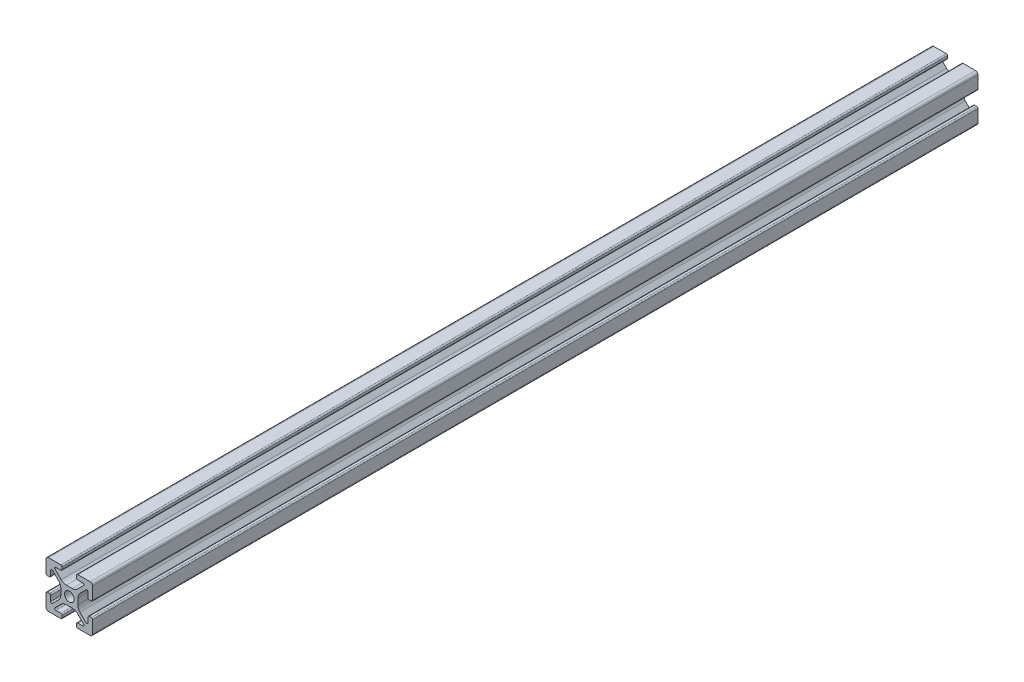
from build123d import *

# Parameters (mm, degrees)
SKETCH2_R           = 2.05
BOSS_EXTRUDE1_DEPTH = 380


with BuildPart() as part:
    # Sketch2 → Boss-Extrude1 (new body)
    with BuildSketch(Plane.XY):
        with BuildLine():
            Line((-3.642230561, 1.287773026), (-3.642230561, -1.287773026))
            ThreePointArc((-3.642230561, -1.287773026), (-3.87999308, -2.483085929), (-4.55708345, -3.496423279))
            Line((-4.55708345, -3.496423279), (-7.182004606, -6.121344434))
            ThreePointArc((-7.182004606, -6.121344434), (-7.704200045, -6.225215565), (-8, -5.782519648))
            Line((-8, -5.782519648), (-8, -3.622007668))
            ThreePointArc((-8, -3.622007668), (-8.161974206, -3.230967343), (-8.553014531, -3.068993137))
            Line((-8.553014531, -3.068993137), (-9.443284204, -3.068993137))
            ThreePointArc((-9.443284204, -3.068993137), (-9.836715763, -3.229656566), (-10, -3.622007668))
            Line((-10, -3.622007668), (-10, -8.939033256))
            ThreePointArc((-10, -8.939033256), (-9.689250035, -9.689250035), (-8.939033256, -10))
            Line((-8.939033256, -10), (-3.622007668, -10))
            ThreePointArc((-3.622007668, -10), (-3.229656566, -9.836715763), (-3.068993137, -9.443284204))
            Line((-3.068993137, -9.443284204), (-3.068993137, -8.553014531))
            ThreePointArc((-3.068993137, -8.553014531), (-3.230967343, -8.161974206), (-3.622007668, -8))
            Line((-3.622007668, -8), (-5.782519648, -8))
            ThreePointArc((-5.782519648, -8), (-6.225215565, -7.704200045), (-6.121344434, -7.182004606))
            Line((-6.121344434, -7.182004606), (-3.496423279, -4.55708345))
            ThreePointArc((-3.496423279, -4.55708345), (-2.483085929, -3.87999308), (-1.287773026, -3.642230561))
            Line((-1.287773026, -3.642230561), (1.287773026, -3.642230561))
            ThreePointArc((1.287773026, -3.642230561), (2.483085929, -3.87999308), (3.496423279, -4.55708345))
            Line((3.496423279, -4.55708345), (6.121344434, -7.182004606))
            ThreePointArc((6.121344434, -7.182004606), (6.225215565, -7.704200045), (5.782519648, -8))
            Line((5.782519648, -8), (3.622007668, -8))
            ThreePointArc((3.622007668, -8), (3.230967343, -8.161974206), (3.068993137, -8.553014531))
            Line((3.068993137, -8.553014531), (3.068993137, -9.443284204))
            ThreePointArc((3.068993137, -9.443284204), (3.229656566, -9.836715763), (3.622007668, -10))
            Line((3.622007668, -10), (8.939033256, -10))
            ThreePointArc((8.939033256, -10), (9.689250035, -9.689250035), (10, -8.939033256))
            Line((10, -8.939033256), (10, -3.622007668))
            ThreePointArc((10, -3.622007668), (9.836715763, -3.229656566), (9.443284204, -3.068993137))
            Line((9.443284204, -3.068993137), (8.553014531, -3.068993137))
            ThreePointArc((8.553014531, -3.068993137), (8.161974206, -3.230967343), (8, -3.622007668))
            Line((8, -3.622007668), (8, -5.782519648))
            ThreePointArc((8, -5.782519648), (7.704200045, -6.225215565), (7.182004606, -6.121344434))
            Line((7.182004606, -6.121344434), (4.55708345, -3.496423279))
            ThreePointArc((4.55708345, -3.496423279), (3.87999308, -2.483085929), (3.642230561, -1.287773026))
            Line((3.642230561, -1.287773026), (3.642230561, 1.287773026))
            ThreePointArc((3.642230561, 1.287773026), (3.87999308, 2.483085929), (4.55708345, 3.496423279))
            Line((4.55708345, 3.496423279), (7.182004606, 6.121344434))
            ThreePointArc((7.182004606, 6.121344434), (7.704200045, 6.225215565), (8, 5.782519648))
            Line((8, 5.782519648), (8, 3.622007668))
            ThreePointArc((8, 3.622007668), (8.161974206, 3.230967343), (8.553014531, 3.068993137))
            Line((8.553014531, 3.068993137), (9.443284204, 3.068993137))
            ThreePointArc((9.443284204, 3.068993137), (9.836715763, 3.229656566), (10, 3.622007668))
            Line((10, 3.622007668), (10, 8.939033256))
            ThreePointArc((10, 8.939033256), (9.689250035, 9.689250035), (8.939033256, 10))
            Line((8.939033256, 10), (3.622007668, 10))
            ThreePointArc((3.622007668, 10), (3.229656566, 9.836715763), (3.068993137, 9.443284204))
            Line((3.068993137, 9.443284204), (3.068993137, 8.553014531))
            ThreePointArc((3.068993137, 8.553014531), (3.230967343, 8.161974206), (3.622007668, 8))
            Line((3.622007668, 8), (5.782519648, 8))
            ThreePointArc((5.782519648, 8), (6.225215565, 7.704200045), (6.121344434, 7.182004606))
            Line((6.121344434, 7.182004606), (3.496423279, 4.55708345))
            ThreePointArc((3.496423279, 4.55708345), (2.483085929, 3.87999308), (1.287773026, 3.642230561))
            Line((1.287773026, 3.642230561), (-1.287773026, 3.642230561))
            ThreePointArc((-1.287773026, 3.642230561), (-2.483085929, 3.87999308), (-3.496423279, 4.55708345))
            Line((-3.496423279, 4.55708345), (-6.121344434, 7.182004606))
            ThreePointArc((-6.121344434, 7.182004606), (-6.225215565, 7.704200045), (-5.782519648, 8))
            Line((-5.782519648, 8), (-3.622007668, 8))
            ThreePointArc((-3.622007668, 8), (-3.230967343, 8.161974206), (-3.068993137, 8.553014531))
            Line((-3.068993137, 8.553014531), (-3.068993137, 9.443284204))
            ThreePointArc((-3.068993137, 9.443284204), (-3.229656566, 9.836715763), (-3.622007668, 10))
            Line((-3.622007668, 10), (-8.939033256, 10))
            ThreePointArc((-8.939033256, 10), (-9.689250035, 9.689250035), (-10, 8.939033256))
            Line((-10, 8.939033256), (-10, 3.622007668))
            ThreePointArc((-10, 3.622007668), (-9.836715763, 3.229656566), (-9.443284204, 3.068993137))
            Line((-9.443284204, 3.068993137), (-8.553014531, 3.068993137))
            ThreePointArc((-8.553014531, 3.068993137), (-8.161974206, 3.230967343), (-8, 3.622007668))
            Line((-8, 3.622007668), (-8, 5.782519648))
            ThreePointArc((-8, 5.782519648), (-7.704200045, 6.225215565), (-7.182004606, 6.121344434))
            Line((-7.182004606, 6.121344434), (-4.55708345, 3.496423279))
            ThreePointArc((-4.55708345, 3.496423279), (-3.87999308, 2.483085929), (-3.642230561, 1.287773026))
        make_face()
        Circle(SKETCH2_R, mode=Mode.SUBTRACT)
    extrude(amount=-BOSS_EXTRUDE1_DEPTH)


solid = part.part
